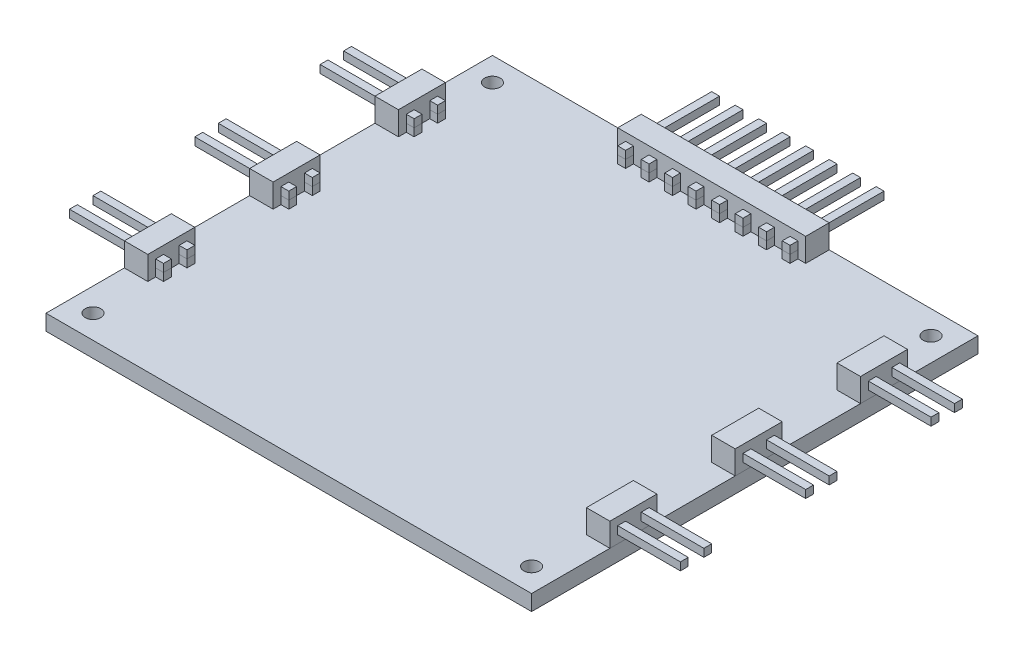
from build123d import *

# Parameters (mm, degrees)
SKETCH1_W              = 49.2125
SKETCH1_H              = 45.24375
BOSS_EXTRUDE2_DEPTH    = 1.5875
SKETCH2_W              = 0.79375
SKETCH2_H              = 0.79375
BOSS_EXTRUDE4_DEPTH    = 0.79375
BOSS_EXTRUDE4_2_DEPTH  = 0.79375
BOSS_EXTRUDE4_3_DEPTH  = 0.79375
BOSS_EXTRUDE4_4_DEPTH  = 0.79375
BOSS_EXTRUDE4_5_DEPTH  = 0.79375
BOSS_EXTRUDE4_6_DEPTH  = 0.79375
BOSS_EXTRUDE4_7_DEPTH  = 0.79375
BOSS_EXTRUDE4_8_DEPTH  = 0.79375
BOSS_EXTRUDE4_9_DEPTH  = 0.79375
BOSS_EXTRUDE4_10_DEPTH = 0.79375
BOSS_EXTRUDE4_11_DEPTH = 0.79375
BOSS_EXTRUDE4_12_DEPTH = 0.79375
BOSS_EXTRUDE5_START    = 0.79375
SKETCH2_3_W            = 9.525
SKETCH2_3_H            = 0.79375
BOSS_EXTRUDE5_DEPTH    = 0.79375
BOSS_EXTRUDE5_2_DEPTH  = 0.79375
BOSS_EXTRUDE5_3_DEPTH  = 0.79375
BOSS_EXTRUDE5_4_DEPTH  = 0.79375
BOSS_EXTRUDE5_5_DEPTH  = 0.79375
BOSS_EXTRUDE5_6_DEPTH  = 0.79375
BOSS_EXTRUDE5_7_DEPTH  = 0.79375
BOSS_EXTRUDE5_8_DEPTH  = 0.79375
BOSS_EXTRUDE5_9_DEPTH  = 0.79375
BOSS_EXTRUDE5_10_DEPTH = 0.79375
BOSS_EXTRUDE5_11_DEPTH = 0.79375
BOSS_EXTRUDE5_12_DEPTH = 0.79375
SKETCH3_W              = 2.38125
SKETCH3_H              = 4.7625
BOSS_EXTRUDE6_DEPTH    = 2.38125
BOSS_EXTRUDE6_2_DEPTH  = 2.38125
BOSS_EXTRUDE6_3_DEPTH  = 2.38125
BOSS_EXTRUDE6_4_DEPTH  = 2.38125
BOSS_EXTRUDE6_5_DEPTH  = 2.38125
BOSS_EXTRUDE6_6_DEPTH  = 2.38125
SKETCH4_W              = 0.79375
SKETCH4_H              = 0.79375
BOSS_EXTRUDE7_DEPTH    = 0.79375
BOSS_EXTRUDE7_2_DEPTH  = 0.79375
BOSS_EXTRUDE7_3_DEPTH  = 0.79375
BOSS_EXTRUDE7_4_DEPTH  = 0.79375
BOSS_EXTRUDE7_5_DEPTH  = 0.79375
BOSS_EXTRUDE7_6_DEPTH  = 0.79375
BOSS_EXTRUDE7_7_DEPTH  = 0.79375
BOSS_EXTRUDE7_8_DEPTH  = 0.79375
BOSS_EXTRUDE8_START    = 0.79375
SKETCH4_3_W            = 0.79375
SKETCH4_3_H            = 9.525
BOSS_EXTRUDE8_DEPTH    = 0.79375
BOSS_EXTRUDE8_2_DEPTH  = 0.79375
BOSS_EXTRUDE8_3_DEPTH  = 0.79375
BOSS_EXTRUDE8_4_DEPTH  = 0.79375
BOSS_EXTRUDE8_5_DEPTH  = 0.79375
BOSS_EXTRUDE8_6_DEPTH  = 0.79375
BOSS_EXTRUDE8_7_DEPTH  = 0.79375
BOSS_EXTRUDE8_8_DEPTH  = 0.79375
SKETCH5_W              = 19.05
SKETCH5_H              = 2.38125
BOSS_EXTRUDE9_DEPTH    = 2.38125
SKETCH12_R             = 0.79375
CUT_EXTRUDE1_DEPTH     = 43.465625


with BuildPart() as part:
    # Sketch1 → Boss-Extrude2 (new body)
    with BuildSketch(Plane(origin=(0, 0, 0), x_dir=(1, 0, 0), z_dir=(0, 1, 0))):
        Rectangle(SKETCH1_W, SKETCH1_H)
    extrude(amount=BOSS_EXTRUDE2_DEPTH)

    # Sketch12 → Cut-Extrude1 (cut, through all)
    with BuildSketch(Plane(origin=(0, 1.5875, 0), x_dir=(1, 0, 0), z_dir=(0, 1, 0))):
        with Locations((-22.225, 20.240625)):
            Circle(SKETCH12_R)
        with Locations((-22.225, -20.240625)):
            Circle(SKETCH12_R)
        with Locations((22.225, -20.240625)):
            Circle(SKETCH12_R)
        with Locations((22.225, 20.240625)):
            Circle(SKETCH12_R)
    extrude(amount=-CUT_EXTRUDE1_DEPTH, mode=Mode.SUBTRACT)


with BuildPart() as body_2:
    # Sketch2 → Boss-Extrude4 (new body)
    with BuildSketch(Plane(origin=(0, 1.5875, 0), x_dir=(1, 0, 0), z_dir=(0, 1, 0))):
        with Locations((21.828125, 14.2875)):
            Rectangle(SKETCH2_W, SKETCH2_H)
    extrude(amount=BOSS_EXTRUDE4_DEPTH)


with BuildPart() as body_3:
    # Sketch2 → Boss-Extrude4 2 (new body)
    with BuildSketch(Plane(origin=(0, 1.5875, 0), x_dir=(1, 0, 0), z_dir=(0, 1, 0))):
        with Locations((21.828125, 11.90625)):
            Rectangle(SKETCH2_W, SKETCH2_H)
    extrude(amount=BOSS_EXTRUDE4_2_DEPTH)


with BuildPart() as body_4:
    # Sketch2 → Boss-Extrude4 3 (new body)
    with BuildSketch(Plane(origin=(0, 1.5875, 0), x_dir=(1, 0, 0), z_dir=(0, 1, 0))):
        with Locations((21.828125, 1.5875)):
            Rectangle(SKETCH2_W, SKETCH2_H)
    extrude(amount=BOSS_EXTRUDE4_3_DEPTH)


with BuildPart() as body_5:
    # Sketch2 → Boss-Extrude4 4 (new body)
    with BuildSketch(Plane(origin=(0, 1.5875, 0), x_dir=(1, 0, 0), z_dir=(0, 1, 0))):
        with Locations((21.828125, -0.79375)):
            Rectangle(SKETCH2_W, SKETCH2_H)
    extrude(amount=BOSS_EXTRUDE4_4_DEPTH)


with BuildPart() as body_6:
    # Sketch2 → Boss-Extrude4 5 (new body)
    with BuildSketch(Plane(origin=(0, 1.5875, 0), x_dir=(1, 0, 0), z_dir=(0, 1, 0))):
        with Locations((21.828125, -11.1125)):
            Rectangle(SKETCH2_W, SKETCH2_H)
    extrude(amount=BOSS_EXTRUDE4_5_DEPTH)


with BuildPart() as body_7:
    # Sketch2 → Boss-Extrude4 6 (new body)
    with BuildSketch(Plane(origin=(0, 1.5875, 0), x_dir=(1, 0, 0), z_dir=(0, 1, 0))):
        with Locations((21.828125, -13.49375)):
            Rectangle(SKETCH2_W, SKETCH2_H)
    extrude(amount=BOSS_EXTRUDE4_6_DEPTH)


with BuildPart() as body_8:
    # Sketch2 → Boss-Extrude4 7 (new body)
    with BuildSketch(Plane(origin=(0, 1.5875, 0), x_dir=(1, 0, 0), z_dir=(0, 1, 0))):
        with Locations((-21.828125, -13.49375)):
            Rectangle(SKETCH2_W, SKETCH2_H)
    extrude(amount=BOSS_EXTRUDE4_7_DEPTH)


with BuildPart() as body_9:
    # Sketch2 → Boss-Extrude4 8 (new body)
    with BuildSketch(Plane(origin=(0, 1.5875, 0), x_dir=(1, 0, 0), z_dir=(0, 1, 0))):
        with Locations((-21.828125, -11.1125)):
            Rectangle(SKETCH2_W, SKETCH2_H)
    extrude(amount=BOSS_EXTRUDE4_8_DEPTH)


with BuildPart() as body_10:
    # Sketch2 → Boss-Extrude4 9 (new body)
    with BuildSketch(Plane(origin=(0, 1.5875, 0), x_dir=(1, 0, 0), z_dir=(0, 1, 0))):
        with Locations((-21.828125, -0.79375)):
            Rectangle(SKETCH2_W, SKETCH2_H)
    extrude(amount=BOSS_EXTRUDE4_9_DEPTH)


with BuildPart() as body_11:
    # Sketch2 → Boss-Extrude4 10 (new body)
    with BuildSketch(Plane(origin=(0, 1.5875, 0), x_dir=(1, 0, 0), z_dir=(0, 1, 0))):
        with Locations((-21.828125, 1.5875)):
            Rectangle(SKETCH2_W, SKETCH2_H)
    extrude(amount=BOSS_EXTRUDE4_10_DEPTH)


with BuildPart() as body_12:
    # Sketch2 → Boss-Extrude4 11 (new body)
    with BuildSketch(Plane(origin=(0, 1.5875, 0), x_dir=(1, 0, 0), z_dir=(0, 1, 0))):
        with Locations((-21.828125, 11.90625)):
            Rectangle(SKETCH2_W, SKETCH2_H)
    extrude(amount=BOSS_EXTRUDE4_11_DEPTH)


with BuildPart() as body_13:
    # Sketch2 → Boss-Extrude4 12 (new body)
    with BuildSketch(Plane(origin=(0, 1.5875, 0), x_dir=(1, 0, 0), z_dir=(0, 1, 0))):
        with Locations((-21.828125, 14.2875)):
            Rectangle(SKETCH2_W, SKETCH2_H)
    extrude(amount=BOSS_EXTRUDE4_12_DEPTH)


with BuildPart() as body_14:
    # Sketch2_3 → Boss-Extrude5 (new body)
    with BuildSketch(Plane(origin=(0, 1.5875, 0), x_dir=(1, 0, 0), z_dir=(0, 1, 0)).offset(BOSS_EXTRUDE5_START)):
        with Locations((26.19375, 14.2875)):
            Rectangle(SKETCH2_3_W, SKETCH2_3_H)
    extrude(amount=BOSS_EXTRUDE5_DEPTH)


with BuildPart() as body_15:
    # Sketch2_3 → Boss-Extrude5 2 (new body)
    with BuildSketch(Plane(origin=(0, 1.5875, 0), x_dir=(1, 0, 0), z_dir=(0, 1, 0)).offset(BOSS_EXTRUDE5_START)):
        with Locations((26.19375, 11.90625)):
            Rectangle(SKETCH2_3_W, SKETCH2_3_H)
    extrude(amount=BOSS_EXTRUDE5_2_DEPTH)


with BuildPart() as body_16:
    # Sketch2_3 → Boss-Extrude5 3 (new body)
    with BuildSketch(Plane(origin=(0, 1.5875, 0), x_dir=(1, 0, 0), z_dir=(0, 1, 0)).offset(BOSS_EXTRUDE5_START)):
        with Locations((26.19375, 1.5875)):
            Rectangle(SKETCH2_3_W, SKETCH2_3_H)
    extrude(amount=BOSS_EXTRUDE5_3_DEPTH)


with BuildPart() as body_17:
    # Sketch2_3 → Boss-Extrude5 4 (new body)
    with BuildSketch(Plane(origin=(0, 1.5875, 0), x_dir=(1, 0, 0), z_dir=(0, 1, 0)).offset(BOSS_EXTRUDE5_START)):
        with Locations((26.19375, -0.79375)):
            Rectangle(SKETCH2_3_W, SKETCH2_3_H)
    extrude(amount=BOSS_EXTRUDE5_4_DEPTH)


with BuildPart() as body_18:
    # Sketch2_3 → Boss-Extrude5 5 (new body)
    with BuildSketch(Plane(origin=(0, 1.5875, 0), x_dir=(1, 0, 0), z_dir=(0, 1, 0)).offset(BOSS_EXTRUDE5_START)):
        with Locations((26.19375, -11.1125)):
            Rectangle(SKETCH2_3_W, SKETCH2_3_H)
    extrude(amount=BOSS_EXTRUDE5_5_DEPTH)


with BuildPart() as body_19:
    # Sketch2_3 → Boss-Extrude5 6 (new body)
    with BuildSketch(Plane(origin=(0, 1.5875, 0), x_dir=(1, 0, 0), z_dir=(0, 1, 0)).offset(BOSS_EXTRUDE5_START)):
        with Locations((26.19375, -13.49375)):
            Rectangle(SKETCH2_3_W, SKETCH2_3_H)
    extrude(amount=BOSS_EXTRUDE5_6_DEPTH)


with BuildPart() as body_20:
    # Sketch2_3 → Boss-Extrude5 7 (new body)
    with BuildSketch(Plane(origin=(0, 1.5875, 0), x_dir=(1, 0, 0), z_dir=(0, 1, 0)).offset(BOSS_EXTRUDE5_START)):
        with Locations((-26.19375, 14.2875)):
            Rectangle(SKETCH2_3_W, SKETCH2_3_H)
    extrude(amount=BOSS_EXTRUDE5_7_DEPTH)


with BuildPart() as body_21:
    # Sketch2_3 → Boss-Extrude5 8 (new body)
    with BuildSketch(Plane(origin=(0, 1.5875, 0), x_dir=(1, 0, 0), z_dir=(0, 1, 0)).offset(BOSS_EXTRUDE5_START)):
        with Locations((-26.19375, 11.90625)):
            Rectangle(SKETCH2_3_W, SKETCH2_3_H)
    extrude(amount=BOSS_EXTRUDE5_8_DEPTH)


with BuildPart() as body_22:
    # Sketch2_3 → Boss-Extrude5 9 (new body)
    with BuildSketch(Plane(origin=(0, 1.5875, 0), x_dir=(1, 0, 0), z_dir=(0, 1, 0)).offset(BOSS_EXTRUDE5_START)):
        with Locations((-26.19375, 1.5875)):
            Rectangle(SKETCH2_3_W, SKETCH2_3_H)
    extrude(amount=BOSS_EXTRUDE5_9_DEPTH)


with BuildPart() as body_23:
    # Sketch2_3 → Boss-Extrude5 10 (new body)
    with BuildSketch(Plane(origin=(0, 1.5875, 0), x_dir=(1, 0, 0), z_dir=(0, 1, 0)).offset(BOSS_EXTRUDE5_START)):
        with Locations((-26.19375, -0.79375)):
            Rectangle(SKETCH2_3_W, SKETCH2_3_H)
    extrude(amount=BOSS_EXTRUDE5_10_DEPTH)


with BuildPart() as body_24:
    # Sketch2_3 → Boss-Extrude5 11 (new body)
    with BuildSketch(Plane(origin=(0, 1.5875, 0), x_dir=(1, 0, 0), z_dir=(0, 1, 0)).offset(BOSS_EXTRUDE5_START)):
        with Locations((-26.19375, -11.1125)):
            Rectangle(SKETCH2_3_W, SKETCH2_3_H)
    extrude(amount=BOSS_EXTRUDE5_11_DEPTH)


with BuildPart() as body_25:
    # Sketch2_3 → Boss-Extrude5 12 (new body)
    with BuildSketch(Plane(origin=(0, 1.5875, 0), x_dir=(1, 0, 0), z_dir=(0, 1, 0)).offset(BOSS_EXTRUDE5_START)):
        with Locations((-26.19375, -13.49375)):
            Rectangle(SKETCH2_3_W, SKETCH2_3_H)
    extrude(amount=BOSS_EXTRUDE5_12_DEPTH)


with BuildPart() as body_26:
    # Sketch3 → Boss-Extrude6 (new body)
    with BuildSketch(Plane(origin=(0, 1.5875, 0), x_dir=(1, 0, 0), z_dir=(0, 1, 0))):
        with Locations((-23.415625, 13.096875)):
            Rectangle(SKETCH3_W, SKETCH3_H)
    extrude(amount=BOSS_EXTRUDE6_DEPTH)


with BuildPart() as body_27:
    # Sketch3 → Boss-Extrude6 2 (new body)
    with BuildSketch(Plane(origin=(0, 1.5875, 0), x_dir=(1, 0, 0), z_dir=(0, 1, 0))):
        with Locations((-23.415625, 0.396875)):
            Rectangle(SKETCH3_W, SKETCH3_H)
    extrude(amount=BOSS_EXTRUDE6_2_DEPTH)


with BuildPart() as body_28:
    # Sketch3 → Boss-Extrude6 3 (new body)
    with BuildSketch(Plane(origin=(0, 1.5875, 0), x_dir=(1, 0, 0), z_dir=(0, 1, 0))):
        with Locations((-23.415625, -12.303125)):
            Rectangle(SKETCH3_W, SKETCH3_H)
    extrude(amount=BOSS_EXTRUDE6_3_DEPTH)


with BuildPart() as body_29:
    # Sketch3 → Boss-Extrude6 4 (new body)
    with BuildSketch(Plane(origin=(0, 1.5875, 0), x_dir=(1, 0, 0), z_dir=(0, 1, 0))):
        with Locations((23.415625, -12.303125)):
            Rectangle(SKETCH3_W, SKETCH3_H)
    extrude(amount=BOSS_EXTRUDE6_4_DEPTH)


with BuildPart() as body_30:
    # Sketch3 → Boss-Extrude6 5 (new body)
    with BuildSketch(Plane(origin=(0, 1.5875, 0), x_dir=(1, 0, 0), z_dir=(0, 1, 0))):
        with Locations((23.415625, 0.396875)):
            Rectangle(SKETCH3_W, SKETCH3_H)
    extrude(amount=BOSS_EXTRUDE6_5_DEPTH)


with BuildPart() as body_31:
    # Sketch3 → Boss-Extrude6 6 (new body)
    with BuildSketch(Plane(origin=(0, 1.5875, 0), x_dir=(1, 0, 0), z_dir=(0, 1, 0))):
        with Locations((23.415625, 13.096875)):
            Rectangle(SKETCH3_W, SKETCH3_H)
    extrude(amount=BOSS_EXTRUDE6_6_DEPTH)


with BuildPart() as body_32:
    # Sketch4 → Boss-Extrude7 (new body)
    with BuildSketch(Plane(origin=(0, 1.5875, 0), x_dir=(1, 0, 0), z_dir=(0, 1, 0))):
        with Locations((8.334375, 19.84375)):
            Rectangle(SKETCH4_W, SKETCH4_H)
    extrude(amount=BOSS_EXTRUDE7_DEPTH)


with BuildPart() as body_33:
    # Sketch4 → Boss-Extrude7 2 (new body)
    with BuildSketch(Plane(origin=(0, 1.5875, 0), x_dir=(1, 0, 0), z_dir=(0, 1, 0))):
        with Locations((-1.190625, 19.84375)):
            Rectangle(SKETCH4_W, SKETCH4_H)
    extrude(amount=BOSS_EXTRUDE7_2_DEPTH)


with BuildPart() as body_34:
    # Sketch4 → Boss-Extrude7 3 (new body)
    with BuildSketch(Plane(origin=(0, 1.5875, 0), x_dir=(1, 0, 0), z_dir=(0, 1, 0))):
        with Locations((-3.571875, 19.84375)):
            Rectangle(SKETCH4_W, SKETCH4_H)
    extrude(amount=BOSS_EXTRUDE7_3_DEPTH)


with BuildPart() as body_35:
    # Sketch4 → Boss-Extrude7 4 (new body)
    with BuildSketch(Plane(origin=(0, 1.5875, 0), x_dir=(1, 0, 0), z_dir=(0, 1, 0))):
        with Locations((-5.953125, 19.84375)):
            Rectangle(SKETCH4_W, SKETCH4_H)
    extrude(amount=BOSS_EXTRUDE7_4_DEPTH)


with BuildPart() as body_36:
    # Sketch4 → Boss-Extrude7 5 (new body)
    with BuildSketch(Plane(origin=(0, 1.5875, 0), x_dir=(1, 0, 0), z_dir=(0, 1, 0))):
        with Locations((-8.334375, 19.84375)):
            Rectangle(SKETCH4_W, SKETCH4_H)
    extrude(amount=BOSS_EXTRUDE7_5_DEPTH)


with BuildPart() as body_37:
    # Sketch4 → Boss-Extrude7 6 (new body)
    with BuildSketch(Plane(origin=(0, 1.5875, 0), x_dir=(1, 0, 0), z_dir=(0, 1, 0))):
        with Locations((5.953125, 19.84375)):
            Rectangle(SKETCH4_W, SKETCH4_H)
    extrude(amount=BOSS_EXTRUDE7_6_DEPTH)


with BuildPart() as body_38:
    # Sketch4 → Boss-Extrude7 7 (new body)
    with BuildSketch(Plane(origin=(0, 1.5875, 0), x_dir=(1, 0, 0), z_dir=(0, 1, 0))):
        with Locations((3.571875, 19.84375)):
            Rectangle(SKETCH4_W, SKETCH4_H)
    extrude(amount=BOSS_EXTRUDE7_7_DEPTH)


with BuildPart() as body_39:
    # Sketch4 → Boss-Extrude7 8 (new body)
    with BuildSketch(Plane(origin=(0, 1.5875, 0), x_dir=(1, 0, 0), z_dir=(0, 1, 0))):
        with Locations((1.190625, 19.84375)):
            Rectangle(SKETCH4_W, SKETCH4_H)
    extrude(amount=BOSS_EXTRUDE7_8_DEPTH)


with BuildPart() as body_40:
    # Sketch4_3 → Boss-Extrude8 (new body)
    with BuildSketch(Plane(origin=(0, 1.5875, 0), x_dir=(1, 0, 0), z_dir=(0, 1, 0)).offset(BOSS_EXTRUDE8_START)):
        with Locations((8.334375, 24.209375)):
            Rectangle(SKETCH4_3_W, SKETCH4_3_H)
    extrude(amount=BOSS_EXTRUDE8_DEPTH)


with BuildPart() as body_41:
    # Sketch4_3 → Boss-Extrude8 2 (new body)
    with BuildSketch(Plane(origin=(0, 1.5875, 0), x_dir=(1, 0, 0), z_dir=(0, 1, 0)).offset(BOSS_EXTRUDE8_START)):
        with Locations((-1.190625, 24.209375)):
            Rectangle(SKETCH4_3_W, SKETCH4_3_H)
    extrude(amount=BOSS_EXTRUDE8_2_DEPTH)


with BuildPart() as body_42:
    # Sketch4_3 → Boss-Extrude8 3 (new body)
    with BuildSketch(Plane(origin=(0, 1.5875, 0), x_dir=(1, 0, 0), z_dir=(0, 1, 0)).offset(BOSS_EXTRUDE8_START)):
        with Locations((-3.571875, 24.209375)):
            Rectangle(SKETCH4_3_W, SKETCH4_3_H)
    extrude(amount=BOSS_EXTRUDE8_3_DEPTH)


with BuildPart() as body_43:
    # Sketch4_3 → Boss-Extrude8 4 (new body)
    with BuildSketch(Plane(origin=(0, 1.5875, 0), x_dir=(1, 0, 0), z_dir=(0, 1, 0)).offset(BOSS_EXTRUDE8_START)):
        with Locations((-5.953125, 24.209375)):
            Rectangle(SKETCH4_3_W, SKETCH4_3_H)
    extrude(amount=BOSS_EXTRUDE8_4_DEPTH)


with BuildPart() as body_44:
    # Sketch4_3 → Boss-Extrude8 5 (new body)
    with BuildSketch(Plane(origin=(0, 1.5875, 0), x_dir=(1, 0, 0), z_dir=(0, 1, 0)).offset(BOSS_EXTRUDE8_START)):
        with Locations((-8.334375, 24.209375)):
            Rectangle(SKETCH4_3_W, SKETCH4_3_H)
    extrude(amount=BOSS_EXTRUDE8_5_DEPTH)


with BuildPart() as body_45:
    # Sketch4_3 → Boss-Extrude8 6 (new body)
    with BuildSketch(Plane(origin=(0, 1.5875, 0), x_dir=(1, 0, 0), z_dir=(0, 1, 0)).offset(BOSS_EXTRUDE8_START)):
        with Locations((5.953125, 24.209375)):
            Rectangle(SKETCH4_3_W, SKETCH4_3_H)
    extrude(amount=BOSS_EXTRUDE8_6_DEPTH)


with BuildPart() as body_46:
    # Sketch4_3 → Boss-Extrude8 7 (new body)
    with BuildSketch(Plane(origin=(0, 1.5875, 0), x_dir=(1, 0, 0), z_dir=(0, 1, 0)).offset(BOSS_EXTRUDE8_START)):
        with Locations((3.571875, 24.209375)):
            Rectangle(SKETCH4_3_W, SKETCH4_3_H)
    extrude(amount=BOSS_EXTRUDE8_7_DEPTH)


with BuildPart() as body_47:
    # Sketch4_3 → Boss-Extrude8 8 (new body)
    with BuildSketch(Plane(origin=(0, 1.5875, 0), x_dir=(1, 0, 0), z_dir=(0, 1, 0)).offset(BOSS_EXTRUDE8_START)):
        with Locations((1.190625, 24.209375)):
            Rectangle(SKETCH4_3_W, SKETCH4_3_H)
    extrude(amount=BOSS_EXTRUDE8_8_DEPTH)


with BuildPart() as body_48:
    # Sketch5 → Boss-Extrude9 (new body)
    with BuildSketch(Plane(origin=(0, 1.5875, 0), x_dir=(1, 0, 0), z_dir=(0, 1, 0))):
        with Locations((0, 21.43125)):
            Rectangle(SKETCH5_W, SKETCH5_H)
    extrude(amount=BOSS_EXTRUDE9_DEPTH)


solid = Compound([part.part, body_2.part, body_3.part, body_4.part, body_5.part, body_6.part, body_7.part, body_8.part, body_9.part, body_10.part, body_11.part, body_12.part, body_13.part, body_14.part, body_15.part, body_16.part, body_17.part, body_18.part, body_19.part, body_20.part, body_21.part, body_22.part, body_23.part, body_24.part, body_25.part, body_26.part, body_27.part, body_28.part, body_29.part, body_30.part, body_31.part, body_32.part, body_33.part, body_34.part, body_35.part, body_36.part, body_37.part, body_38.part, body_39.part, body_40.part, body_41.part, body_42.part, body_43.part, body_44.part, body_45.part, body_46.part, body_47.part, body_48.part])
